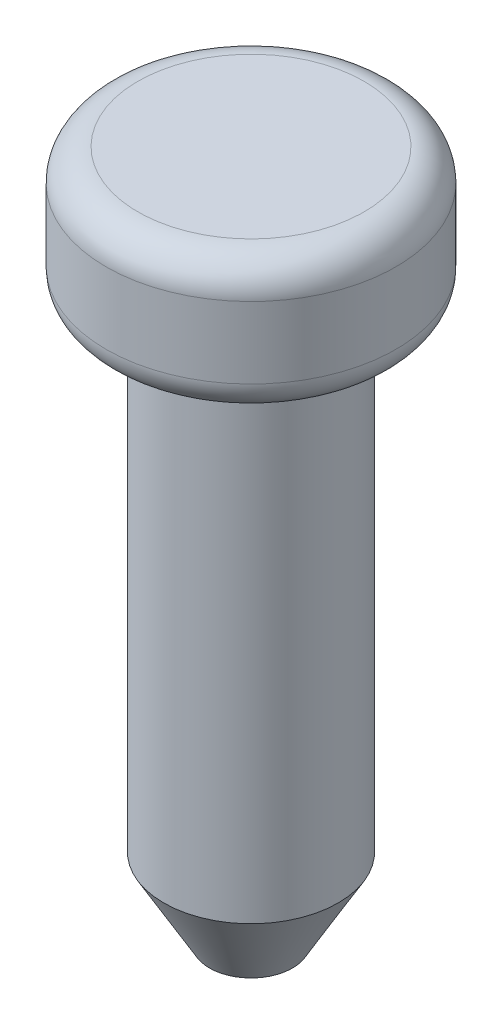
from build123d import *

# Parameters (mm, degrees)
FILLET1_R      = 0.4
CHAMFER1_SIZE  = 1
CHAMFER1_SIZE2 = 0.577350269


with BuildPart() as part:
    # Sketch1 → Revolve2 (revolve)
    with BuildSketch(Plane.XY):
        Polygon((0, 0), (0, 8.7), (-1.825, 8.7), (-1.825, 7), (-1.1, 7), (-1.1, 0), align=None)
    revolve(axis=Axis((0, 0, 0), (0, 1, 0)))

    # Fillet1
    fillet1_edges = [part.edges().sort_by_distance(p)[0] for p in [
        (1.825, 7, 0),
        (1.825, 8.7, 0),
    ]]
    fillet(fillet1_edges, radius=FILLET1_R)

    # Chamfer1
    chamfer1_edges = [part.edges().sort_by_distance(p)[0] for p in [
        (1.1, 0, 0),
    ]]
    chamfer1_side = [part.faces().sort_by_distance(p)[0] for p in [
        (1.1, 3.5, 0),
    ]]
    chamfer(chamfer1_edges, length=CHAMFER1_SIZE, length2=CHAMFER1_SIZE2, reference=chamfer1_side[0])


solid = part.part
